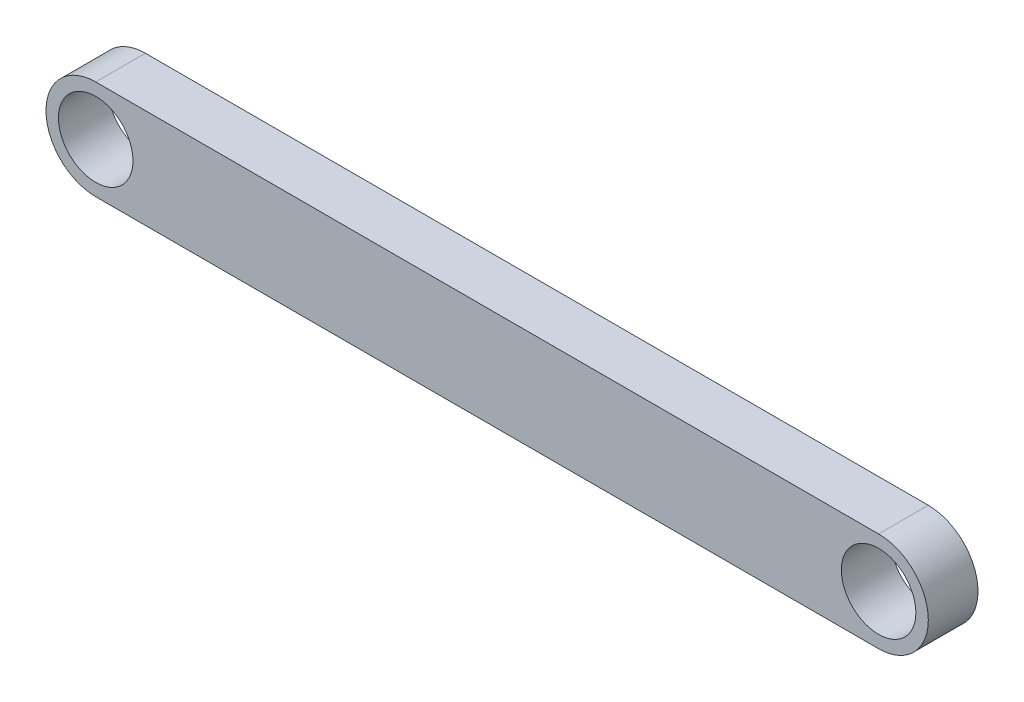
from build123d import *

# Parameters (mm, degrees)
SKETCH_7_R      = 15
EXTRUDE_4_DEPTH = 10


with BuildPart() as part:
    # 草圖7 → 填料-伸長4 (new, symmetric)
    with BuildSketch(Plane.XY):
        with BuildLine():
            Line((157.5, -20), (-157.5, -20))
            ThreePointArc((-157.5, -20), (-177.5, 0), (-157.5, 20))
            Line((-157.5, 20), (157.5, 20))
            ThreePointArc((157.5, 20), (177.5, 0), (157.5, -20))
        make_face()
        with Locations((-157.5, 0)):
            Circle(SKETCH_7_R, mode=Mode.SUBTRACT)
        with Locations((157.5, 0)):
            Circle(SKETCH_7_R, mode=Mode.SUBTRACT)
    extrude(amount=EXTRUDE_4_DEPTH, both=True)


solid = part.part
